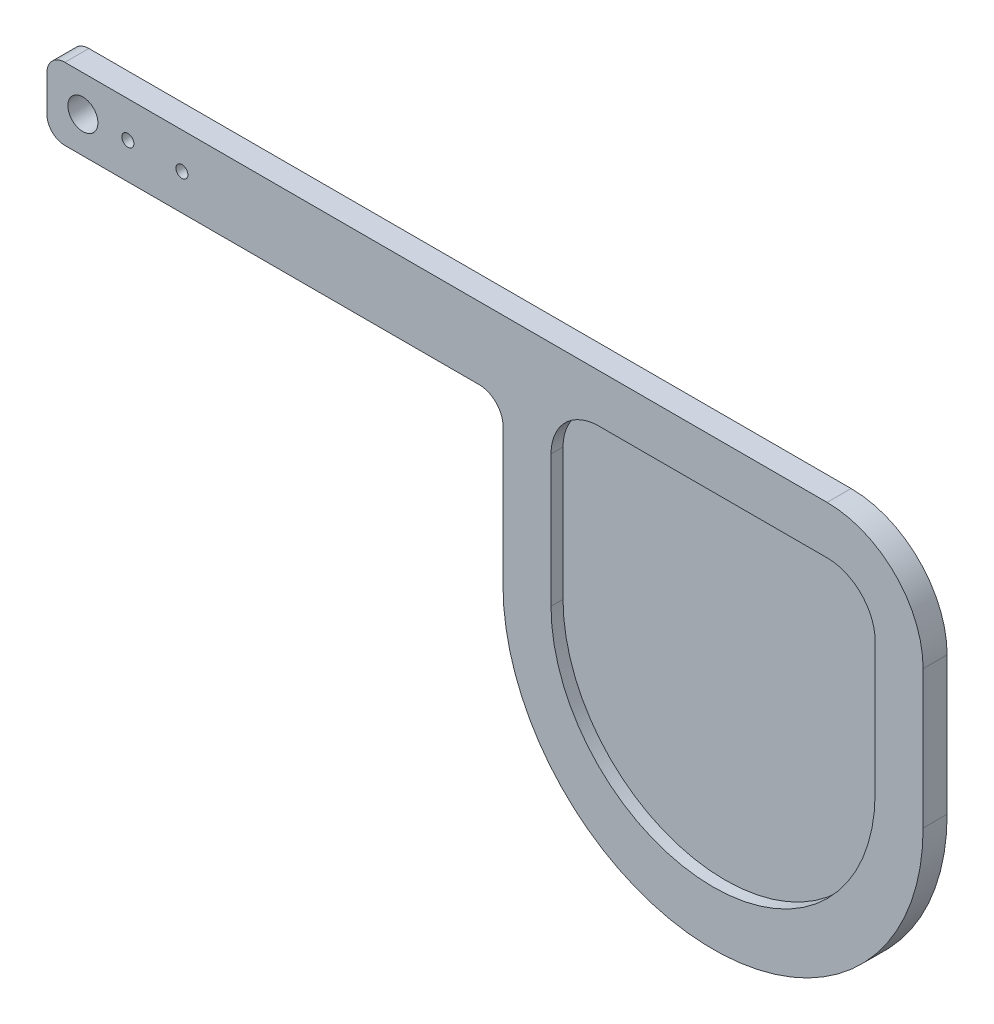
from build123d import *

# Parameters (mm, degrees)
SKETCH_1_R          = 2.5
SKETCH_1_R_2        = 1
EXTRUDE_1_DEPTH     = 4
CUT_EXTRUDE_1_DEPTH = 2


with BuildPart() as part:
    # Эскиз1 → Бобышка-Вытянуть1 (new body)
    with BuildSketch(Plane.XY):
        with BuildLine():
            Line((3, 0), (72, 0))
            ThreePointArc((72, 0), (74.828427125, -1.171572875), (76, -4))
            Line((76, -4), (76, -27))
            ThreePointArc((76, -27), (111, -62), (146, -27))
            Line((146, -27), (146, -4))
            ThreePointArc((146, -4), (141.313708499, 7.313708499), (130, 12))
            Line((130, 12), (3, 12))
            ThreePointArc((3, 12), (0.878679656, 11.121320344), (0, 9))
            Line((0, 9), (0, 3))
            ThreePointArc((0, 3), (0.878679656, 0.878679656), (3, 0))
        make_face()
        with Locations((6, 6)):
            Circle(SKETCH_1_R, mode=Mode.SUBTRACT)
        with Locations((13.5, 6)):
            Circle(SKETCH_1_R_2, mode=Mode.SUBTRACT)
        with Locations((22.5, 6)):
            Circle(SKETCH_1_R_2, mode=Mode.SUBTRACT)
    extrude(amount=EXTRUDE_1_DEPTH)

    # Эскиз2 → Вырез-Вытянуть1 (cut)
    with BuildSketch(Plane.XY.offset(4)):
        with BuildLine():
            Line((92, 4), (130, 4))
            ThreePointArc((130, 4), (135.656854249, 1.656854249), (138, -4))
            Line((138, -4), (138, -26))
            ThreePointArc((138, -26), (111, -53), (84, -26))
            Line((84, -26), (84, -4))
            ThreePointArc((84, -4), (86.343145751, 1.656854249), (92, 4))
        make_face()
    extrude(amount=-CUT_EXTRUDE_1_DEPTH, mode=Mode.SUBTRACT)


solid = part.part
